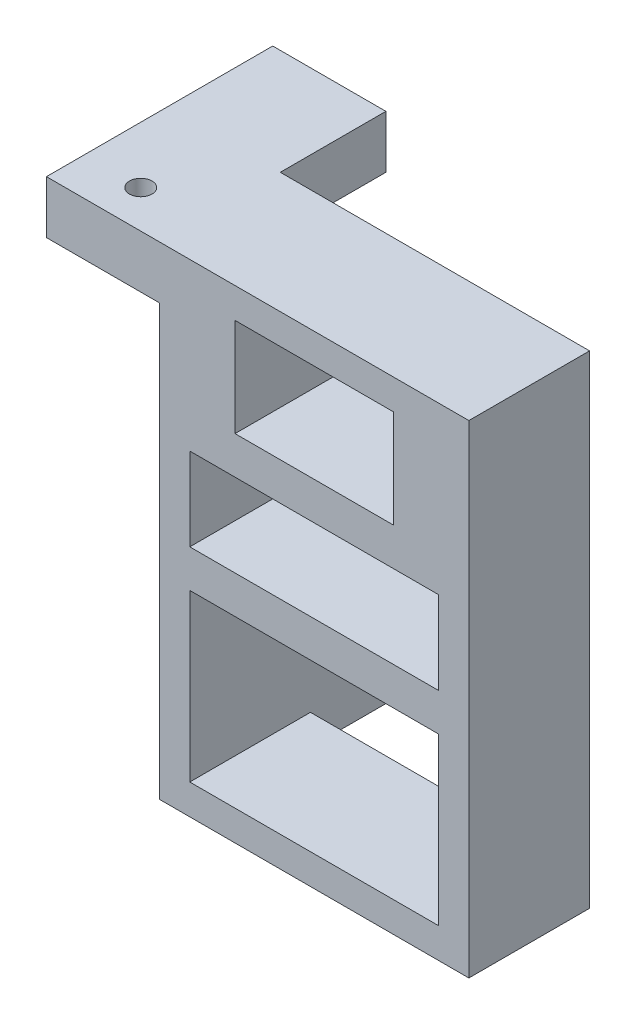
from build123d import *

# Parameters (mm, degrees)
CROQUIS1_W              = 41
CROQUIS1_H              = 64
CROQUIS1_W_2            = 33
CROQUIS1_H_2            = 22
CROQUIS1_H_3            = 11
CROQUIS1_W_3            = 21
CROQUIS1_H_4            = 13
SALIENTE_EXTRUIR1_DEPTH = 16
CROQUIS2_W              = 30
CROQUIS2_H              = 7
SALIENTE_EXTRUIR2_DEPTH = 15
SALIENTE_EXTRUIR3_DEPTH = 22
CROQUIS4_W              = 4
CROQUIS4_H              = 36
SALIENTE_EXTRUIR4_DEPTH = 19
CORTAR_EXTRUIR3_START   = -7
CROQUIS5_R              = 1.5
CORTAR_EXTRUIR3_DEPTH   = 7
CROQUIS7_R              = 1.5
CORTAR_EXTRUIR6_DEPTH   = 4


with BuildPart() as part:
    # Croquis1 → Saliente-Extruir1 (new body)
    with BuildSketch(Plane.XY):
        with Locations((-82.994239819, 12.027777778)):
            Rectangle(CROQUIS1_W, CROQUIS1_H)
        with Locations((-82.994239819, -4.972222222)):
            Rectangle(CROQUIS1_W_2, CROQUIS1_H_2, mode=Mode.SUBTRACT)
        with Locations((-82.994239819, 16.527777778)):
            Rectangle(CROQUIS1_W_2, CROQUIS1_H_3, mode=Mode.SUBTRACT)
        with Locations((-82.994239819, 33.527777778)):
            Rectangle(CROQUIS1_W_3, CROQUIS1_H_4, mode=Mode.SUBTRACT)
    extrude(amount=SALIENTE_EXTRUIR1_DEPTH)

    # Croquis2 → Saliente-Extruir2 (add)
    with BuildSketch(Plane.ZY.offset(103.494239819)):
        with Locations((1, 40.527777778)):
            Rectangle(CROQUIS2_W, CROQUIS2_H)
    extrude(amount=SALIENTE_EXTRUIR2_DEPTH)

    # Croquis3 → Saliente-Extruir3 (add)
    with BuildSketch(Plane(origin=(0, 0, 0), x_dir=(-1, 0, 0), z_dir=(0, 0, -1))):
        Polygon((103.494239819, -19.972222222), (99.494239819, -19.972222222), (99.494239819, 6.027777778), (99.494239819, 16.027777778), (103.494239819, 16.027777778), (103.494239819, 6.027777778), align=None)
    extrude(amount=SALIENTE_EXTRUIR3_DEPTH)

    # Croquis4 → Saliente-Extruir4 (add)
    with BuildSketch(Plane(origin=(-99.494239819, 0, 0), x_dir=(0, 0, -1), z_dir=(1, 0, 0))):
        with Locations((24, -1.972222222)):
            Rectangle(CROQUIS4_W, CROQUIS4_H)
    extrude(amount=-SALIENTE_EXTRUIR4_DEPTH)

    # Croquis5 → Cortar-Extruir3 (cut)
    with BuildSketch(Plane(origin=(0, 44.027777778, 0), x_dir=(1, 0, 0), z_dir=(0, 1, 0)).offset(CORTAR_EXTRUIR3_START)):
        with Locations((-110.994239819, -11)):
            Circle(CROQUIS5_R)
    extrude(amount=CORTAR_EXTRUIR3_DEPTH, mode=Mode.SUBTRACT)

    # Croquis7 → Cortar-Extruir6 (cut)
    with BuildSketch(Plane.XY.offset(-22)):
        with Locations((-110.994239819, 5.027777778)):
            Circle(CROQUIS7_R)
    extrude(amount=-CORTAR_EXTRUIR6_DEPTH, mode=Mode.SUBTRACT)


solid = part.part
